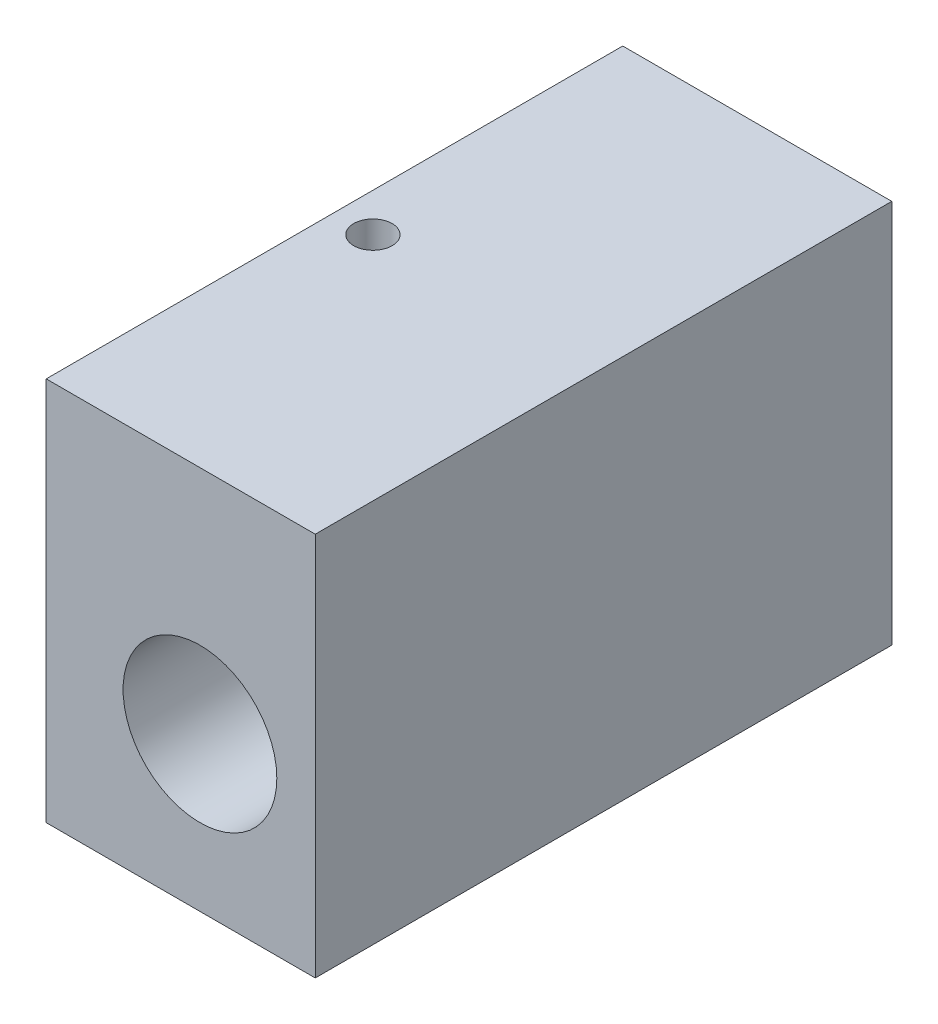
from build123d import *

# Parameters (mm, degrees)
SKETCH_1_W          = 7
SKETCH_1_H          = 15
EXTRUDE_1_DEPTH     = 10
SKETCH_2_R          = 2
CUT_EXTRUDE_1_DEPTH = 16
SKETCH_3_R          = 0.5
CUT_EXTRUDE_2_DEPTH = 8


with BuildPart() as part:
    # 草图1 → 凸台-拉伸1 (new body)
    with BuildSketch(Plane(origin=(0, 0, 0), x_dir=(1, 0, 0), z_dir=(0, 1, 0))):
        with Locations((3.5, 7.5)):
            Rectangle(SKETCH_1_W, SKETCH_1_H)
    extrude(amount=EXTRUDE_1_DEPTH)

    # 草图2 → 切除-拉伸1 (cut, through all)
    with BuildSketch(Plane.XY):
        with Locations((4, 4)):
            Circle(SKETCH_2_R)
    extrude(amount=-CUT_EXTRUDE_1_DEPTH, mode=Mode.SUBTRACT)

    # 草图3 → 切除-拉伸2 (cut)
    with BuildSketch(Plane(origin=(0, 10, 0), x_dir=(1, 0, 0), z_dir=(0, 1, 0))):
        with Locations((1, 7.5)):
            Circle(SKETCH_3_R)
    extrude(amount=-CUT_EXTRUDE_2_DEPTH, mode=Mode.SUBTRACT)


solid = part.part
